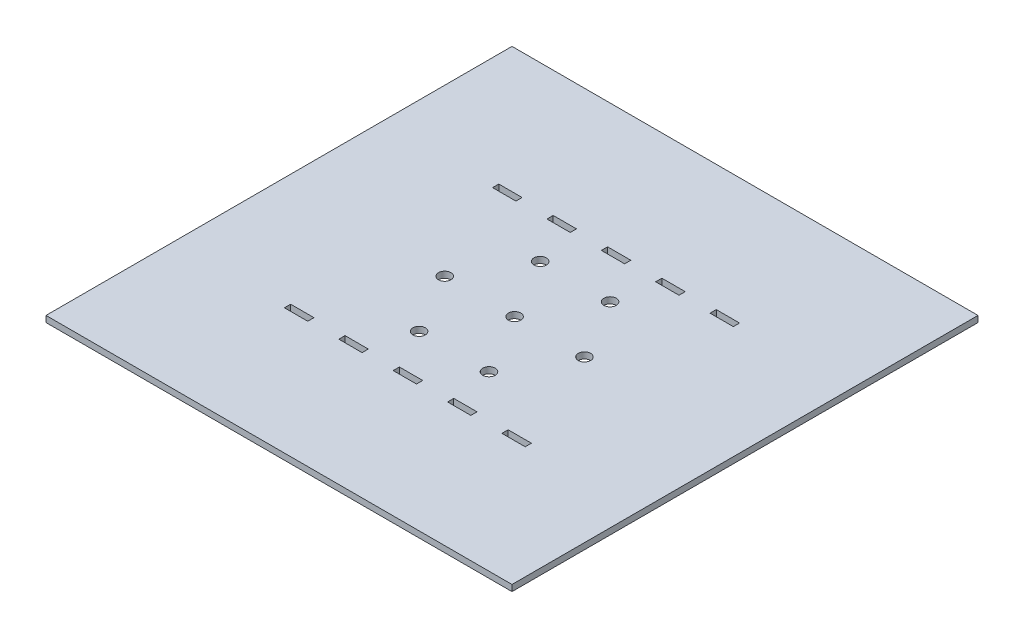
from build123d import *

# Parameters (mm, degrees)
SKETCH1_W           = 300
SKETCH1_H           = 300
SKETCH1_R           = 4
SKETCH1_W_2         = 15
SKETCH1_H_2         = 4
BOSS_EXTRUDE1_DEPTH = 4


with BuildPart() as part:
    # Sketch1 → Boss-Extrude1 (new body)
    with BuildSketch(Plane(origin=(0, 0, 0), x_dir=(1, 0, 0), z_dir=(0, 1, 0))):
        with Locations((-1.47665027, -0.17639355)):
            Rectangle(SKETCH1_W, SKETCH1_H)
        with Locations((-1e-09, 3e-09)):
            Circle(SKETCH1_R, mode=Mode.SUBTRACT)
        with Locations((44.999999999, 3e-09)):
            Circle(SKETCH1_R, mode=Mode.SUBTRACT)
        with Locations((22.499999999, 38.971143173)):
            Circle(SKETCH1_R, mode=Mode.SUBTRACT)
        with Locations((-22.500000001, 38.971143173)):
            Circle(SKETCH1_R, mode=Mode.SUBTRACT)
        with Locations((-45.000000001, 3e-09)):
            Circle(SKETCH1_R, mode=Mode.SUBTRACT)
        with Locations((-22.500000001, -38.971143168)):
            Circle(SKETCH1_R, mode=Mode.SUBTRACT)
        with Locations((22.499999999, -38.971143168)):
            Circle(SKETCH1_R, mode=Mode.SUBTRACT)
        with Locations((-71.47665027, 66.82360645)):
            Rectangle(SKETCH1_W_2, SKETCH1_H_2, mode=Mode.SUBTRACT)
        with Locations((-36.47665027, 66.82360645)):
            Rectangle(SKETCH1_W_2, SKETCH1_H_2, mode=Mode.SUBTRACT)
        with Locations((-1.47665027, 66.82360645)):
            Rectangle(SKETCH1_W_2, SKETCH1_H_2, mode=Mode.SUBTRACT)
        with Locations((33.52334973, 66.82360645)):
            Rectangle(SKETCH1_W_2, SKETCH1_H_2, mode=Mode.SUBTRACT)
        with Locations((68.52334973, 66.82360645)):
            Rectangle(SKETCH1_W_2, SKETCH1_H_2, mode=Mode.SUBTRACT)
        with Locations((68.52334973, -67.17639355)):
            Rectangle(SKETCH1_W_2, SKETCH1_H_2, mode=Mode.SUBTRACT)
        with Locations((33.52334973, -67.17639355)):
            Rectangle(SKETCH1_W_2, SKETCH1_H_2, mode=Mode.SUBTRACT)
        with Locations((-1.47665027, -67.17639355)):
            Rectangle(SKETCH1_W_2, SKETCH1_H_2, mode=Mode.SUBTRACT)
        with Locations((-36.47665027, -67.17639355)):
            Rectangle(SKETCH1_W_2, SKETCH1_H_2, mode=Mode.SUBTRACT)
        with Locations((-71.47665027, -67.17639355)):
            Rectangle(SKETCH1_W_2, SKETCH1_H_2, mode=Mode.SUBTRACT)
    extrude(amount=BOSS_EXTRUDE1_DEPTH)


solid = part.part
